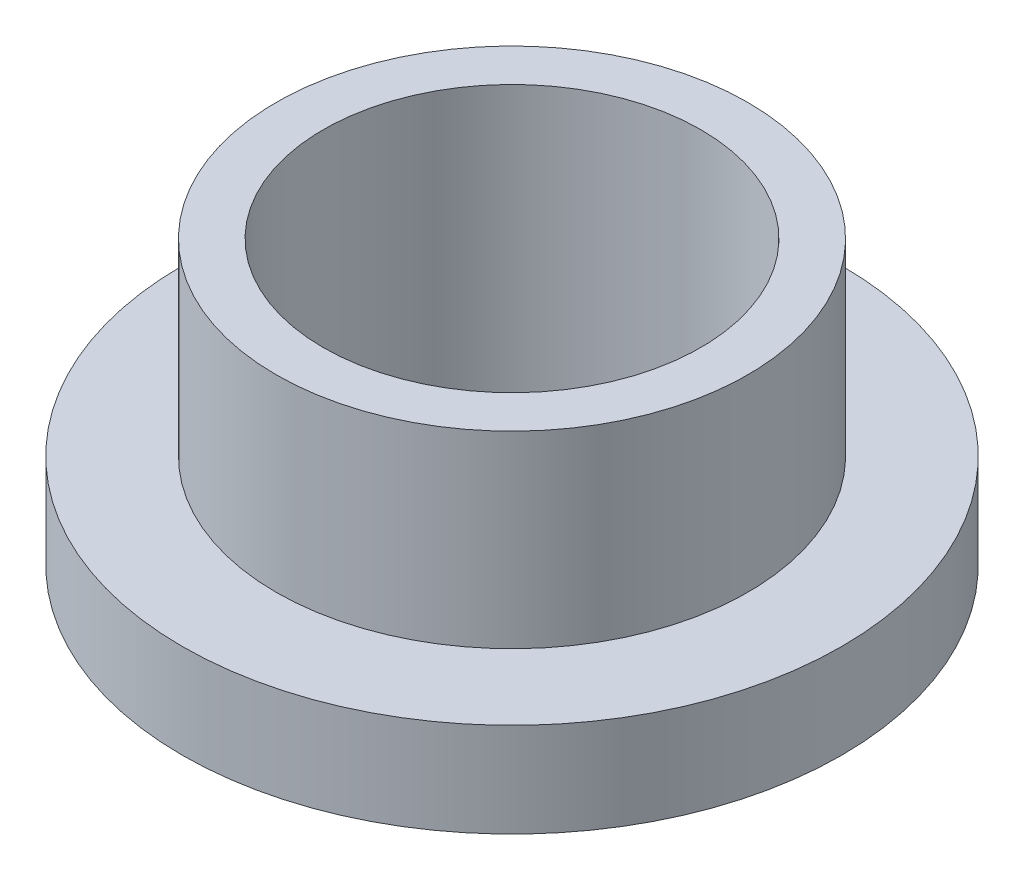
from build123d import *

# Parameters (mm, degrees)
SKETCH2_R           = 7.9502
SKETCH2_R_2         = 6.3627
BOSS_EXTRUDE1_DEPTH = 9.525
SKETCH3_R           = 11.1125
SKETCH3_R_2         = 7.9502
BOSS_EXTRUDE2_DEPTH = 3.175


with BuildPart() as part:
    # Sketch2 → Boss-Extrude1 (new body)
    with BuildSketch(Plane(origin=(0, 0, 0), x_dir=(1, 0, 0), z_dir=(0, 1, 0))):
        Circle(SKETCH2_R)
        Circle(SKETCH2_R_2, mode=Mode.SUBTRACT)
    extrude(amount=BOSS_EXTRUDE1_DEPTH)

    # Sketch3 → Boss-Extrude2 (add)
    with BuildSketch(Plane(origin=(0, 0, 0), x_dir=(1, 0, 0), z_dir=(0, 1, 0))):
        Circle(SKETCH3_R)
        Circle(SKETCH3_R_2, mode=Mode.SUBTRACT)
    extrude(amount=BOSS_EXTRUDE2_DEPTH)


solid = part.part
